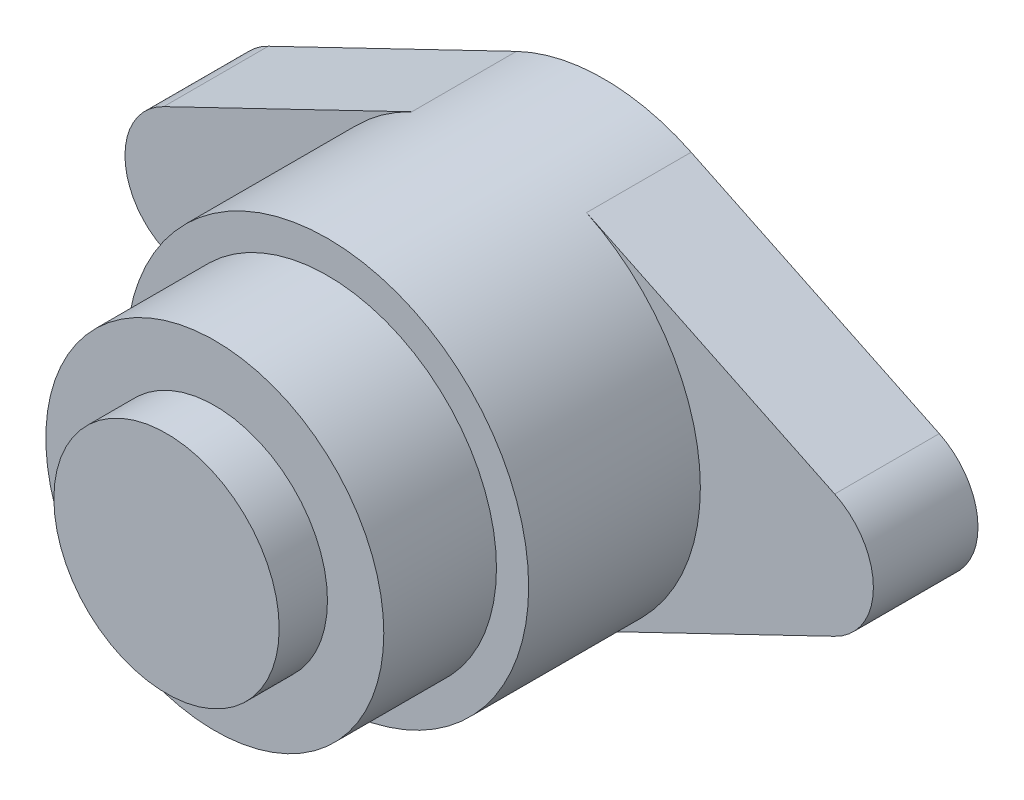
from build123d import *

# Parameters (mm, degrees)
BOSS_EXTRUDE1_DEPTH = 6.5
SKETCH2_R           = 12.5
BOSS_EXTRUDE2_DEPTH = 10.668
SKETCH3_R           = 10.5
BOSS_EXTRUDE3_DEPTH = 7
SKETCH4_R           = 7
BOSS_EXTRUDE4_DEPTH = 3


with BuildPart() as part:
    # Sketch1 → Boss-Extrude1 (new body)
    with BuildSketch(Plane.XY):
        with BuildLine():
            Line((-20.845394737, 3.828448545), (-5.427631579, 11.260142781))
            ThreePointArc((-5.427631579, 11.260142781), (0, 12.5), (5.427631579, 11.260142781))
            Line((5.427631579, 11.260142781), (20.845394737, 3.828448545))
            ThreePointArc((20.845394737, 3.828448545), (23.25, 0), (20.845394737, -3.828448545))
            Line((20.845394737, -3.828448545), (5.427631579, -11.260142781))
            ThreePointArc((5.427631579, -11.260142781), (0, -12.5), (-5.427631579, -11.260142781))
            Line((-5.427631579, -11.260142781), (-20.845394737, -3.828448545))
            ThreePointArc((-20.845394737, -3.828448545), (-23.25, 0), (-20.845394737, 3.828448545))
        make_face()
    extrude(amount=BOSS_EXTRUDE1_DEPTH)

    # Sketch2 → Boss-Extrude2 (add)
    with BuildSketch(Plane.XY.offset(6.5)):
        Circle(SKETCH2_R)
    extrude(amount=BOSS_EXTRUDE2_DEPTH)

    # Sketch3 → Boss-Extrude3 (add)
    with BuildSketch(Plane.XY.offset(17.168)):
        Circle(SKETCH3_R)
    extrude(amount=BOSS_EXTRUDE3_DEPTH)

    # Sketch4 → Boss-Extrude4 (add)
    with BuildSketch(Plane.XY.offset(24.168)):
        Circle(SKETCH4_R)
    extrude(amount=BOSS_EXTRUDE4_DEPTH)


solid = part.part
